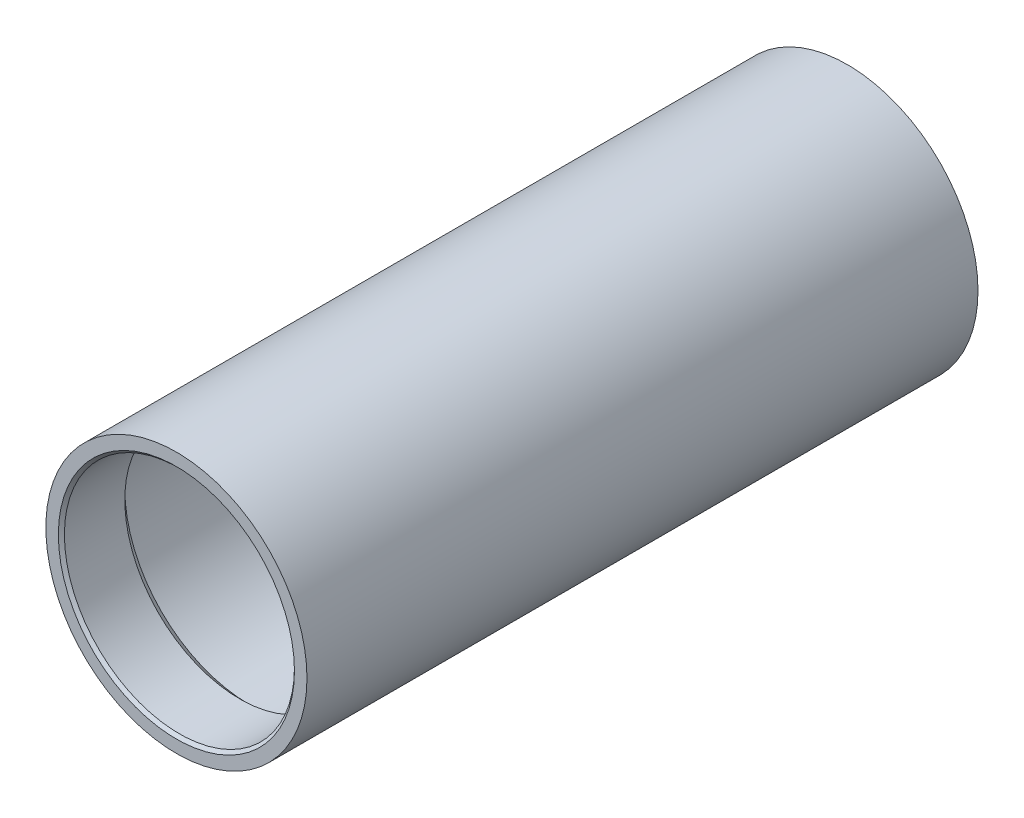
from build123d import *

# Parameters (mm, degrees)
CHAMFER1_SIZE = 1


with BuildPart() as part:
    # Sketch1 → Revolve1 (revolve)
    with BuildSketch(Plane(origin=(0, 0, 0), x_dir=(0, 0, -1), z_dir=(1, 0, 0))):
        Polygon((0, 43.2435), (222.25, 43.2435), (222.25, 38.1), (201.25, 38.1), (198.0115, 41.3385), (115.4635, 41.3385), (113.625, 39.5), (108.625, 39.5), (106.7865, 41.3385), (24.2385, 41.3385), (21, 38.1), (0, 38.1), align=None)
    revolve(axis=Axis((0, 0, 0), (0, 0, -1)))

    # Chamfer1
    chamfer1_edges = [part.edges().sort_by_distance(p)[0] for p in [
        (0, -38.1, 0),
        (0, -38.1, -222.25),
    ]]
    chamfer(chamfer1_edges, length=CHAMFER1_SIZE)


solid = part.part
